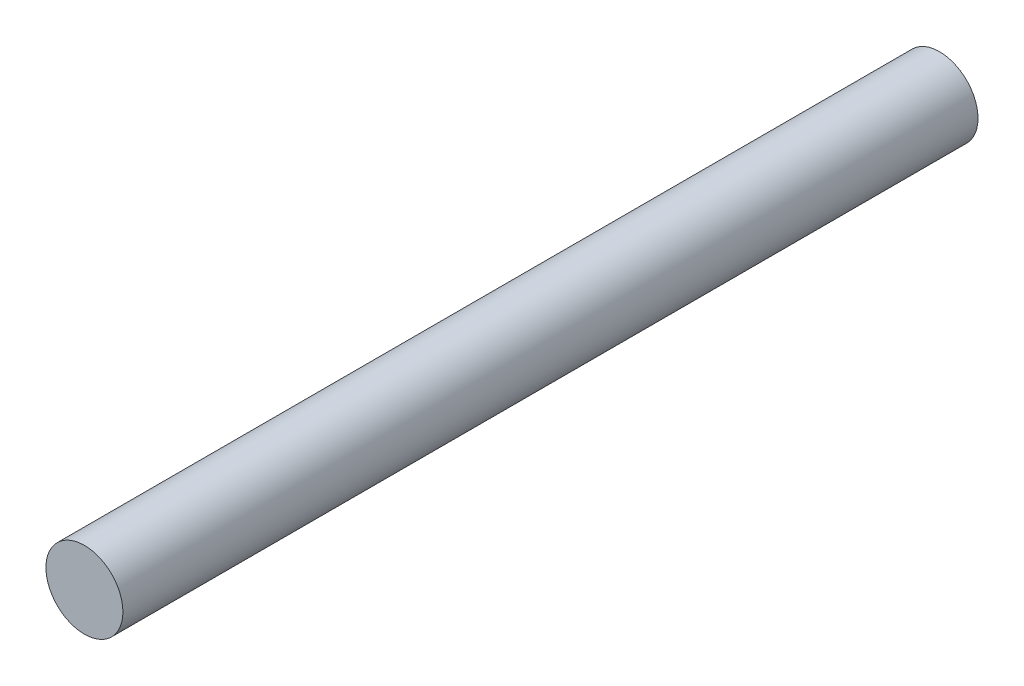
from build123d import *

# Parameters (mm, degrees)
SKETCH2_R           = 3.175
BOSS_EXTRUDE1_DEPTH = 70.53072


with BuildPart() as part:
    # Sketch2 → Boss-Extrude1 (new body)
    with BuildSketch(Plane.XY.offset(179.16652)):
        with Locations((-336.55, 927.1)):
            Circle(SKETCH2_R)
    extrude(amount=-BOSS_EXTRUDE1_DEPTH)


solid = part.part
